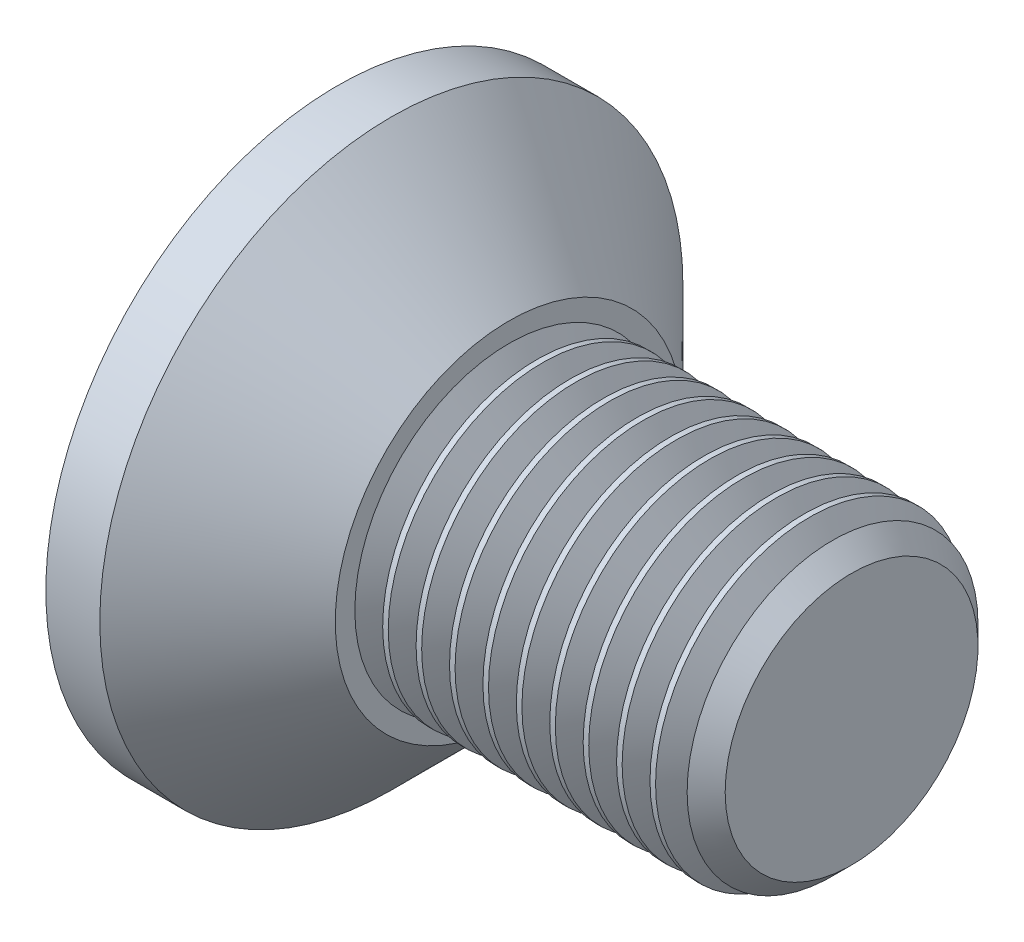
from build123d import *

# Parameters (mm, degrees)
HEXAGONSOCKET_DEPTH = 2.2
HEADFILLET_R        = 0.25
CHAMFER_2_SIZE      = 0.5415
SKETCH4_W           = 5
SKETCH4_H           = 5
LPATTERN10_COUNT    = 10
LPATTERN10_PITCH    = 0.6498


with BuildPart() as part:
    # Sketch1 → Base (revolve)
    with BuildSketch(Plane.XY):
        Polygon((0, 0), (0, 6.72), (3.72, 3), (10, 3), (10, 0), align=None)
    revolve(axis=Axis((-0.587069181, 0, 0), (1, 0, 0)))

    # Sketch2 → HexagonSocket (cut)
    with BuildSketch(Plane(origin=(0, 0, 0), x_dir=(0, 0, -1), z_dir=(1, 0, 0))):
        Polygon((2.309401077, 0), (1.154700538, 2), (-1.154700538, 2), (-2.309401077, 0), (-1.154700538, -2), (1.154700538, -2), align=None)
    extrude(amount=HEXAGONSOCKET_DEPTH, mode=Mode.SUBTRACT)

    # Sketch3 → Cut-Revolve1 (revolve, cut)
    with BuildSketch(Plane.XY):
        Polygon((2.2, 2), (3.354700538, 0), (2.2, 0), align=None)
    revolve(axis=Axis((-0.439109555, 0, 0), (1, 0, 0)), mode=Mode.SUBTRACT)

    # HeadFillet
    headfillet_edges = [part.edges().sort_by_distance(p)[0] for p in [
        (3.72, -3, 0),
    ]]
    fillet(headfillet_edges, radius=HEADFILLET_R)

    # Chamfer 2
    chamfer_2_edges = [part.edges().sort_by_distance(p)[0] for p in [
        (10, -3, 0),
    ]]
    chamfer(chamfer_2_edges, length=CHAMFER_2_SIZE)

    # Sketch4 → Cut-Revolve2 (revolve, cut)
    with BuildSketch(Plane(origin=(0, 0, 0), x_dir=(1, 0, 0), z_dir=(0, 1, 0))):
        with Locations((0.5, 8.17)):
            Rectangle(SKETCH4_W, SKETCH4_H)
    revolve(axis=Axis((11.853138686, 0, 0), (-1, 0, 0)), mode=Mode.SUBTRACT)

    # Sketch5 → Cut-Revolve10 (revolve, cut)
    with BuildSketch(Plane.XY):
        Polygon((9.4585, 2.531047244), (9.72925, 3), (9.72925, 3.5415), (9.18775, 3.5415), (9.18775, 3), align=None)
    cut_revolve10 = revolve(axis=Axis((0, 0, 0), (1, 0, 0)), mode=Mode.SUBTRACT)

    # LPattern10: Cut-Revolve10 ×10
    with Locations(*[(-i * LPATTERN10_PITCH, 0, 0) for i in range(1, LPATTERN10_COUNT)]):
        add(cut_revolve10, mode=Mode.SUBTRACT)


solid = part.part
